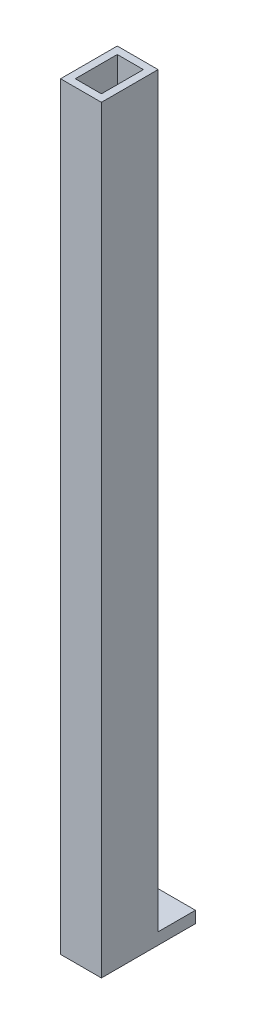
from build123d import *

# Parameters (mm, degrees)
SKETCH1_W           = 11.112
SKETCH1_H           = 15.43
SKETCH1_W_2         = 7.112
SKETCH1_H_2         = 11.43
BOSS_EXTRUDE1_DEPTH = 203.2
SKETCH2_W           = 11.112
SKETCH2_H           = 25.59
SKETCH2_W_2         = 7.112
SKETCH2_H_2         = 11.43
BOSS_EXTRUDE2_DEPTH = 3.175


with BuildPart() as part:
    # Sketch1 → Boss-Extrude1 (new body)
    with BuildSketch(Plane(origin=(0, 0, 0), x_dir=(1, 0, 0), z_dir=(0, 1, 0))):
        with Locations((5.556, 7.715)):
            Rectangle(SKETCH1_W, SKETCH1_H)
        with Locations((5.556, 7.715)):
            Rectangle(SKETCH1_W_2, SKETCH1_H_2, mode=Mode.SUBTRACT)
    extrude(amount=BOSS_EXTRUDE1_DEPTH)

    # Sketch2 → Boss-Extrude2 (add)
    with BuildSketch(Plane.XZ):
        with Locations((5.556, -12.795)):
            Rectangle(SKETCH2_W, SKETCH2_H)
        with Locations((5.556, -7.715)):
            Rectangle(SKETCH2_W_2, SKETCH2_H_2, mode=Mode.SUBTRACT)
    extrude(amount=BOSS_EXTRUDE2_DEPTH)


solid = part.part
